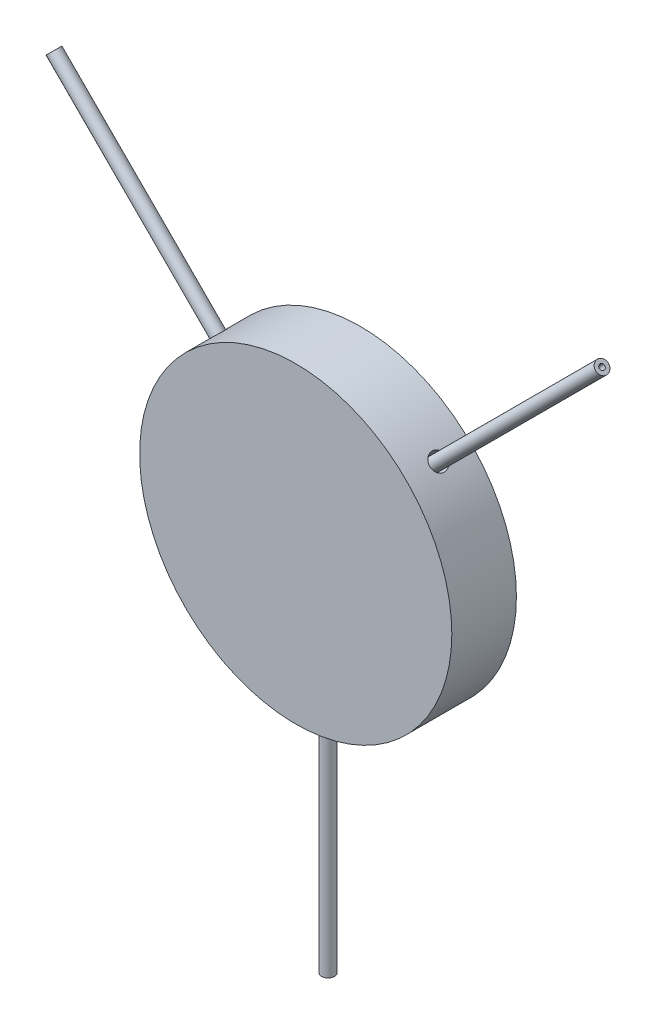
from build123d import *

# Parameters (mm, degrees)
SKETCH1_R           = 7.25
BOSS_EXTRUDE1_DEPTH = 3
CUT_EXTRUDE1_REACH  = 9.25
SKETCH2_R           = 0.4
CUT_EXTRUDE2_REACH  = 12.253
SKETCH3_R           = 0.4
CUT_EXTRUDE3_REACH  = 12.253
SKETCH4_R           = 0.4
BOSS_EXTRUDE2_START = 5
SKETCH5_R           = 0.3
SKETCH5_R_2         = 0.125
BOSS_EXTRUDE2_DEPTH = 13
BOSS_EXTRUDE3_START = 5
SKETCH6_R           = 0.3
SKETCH6_R_2         = 0.125
BOSS_EXTRUDE3_DEPTH = 13
BOSS_EXTRUDE4_START = -5
SKETCH7_R           = 0.3
SKETCH7_R_2         = 0.125
BOSS_EXTRUDE4_DEPTH = 13


with BuildPart() as part:
    # Sketch1 → Boss-Extrude1 (new body)
    with BuildSketch(Plane.XY):
        Circle(SKETCH1_R)
    extrude(amount=BOSS_EXTRUDE1_DEPTH)

    # Sketch2 → Cut-Extrude1 (cut, up to next)
    with BuildSketch(Plane(origin=(0, 0, 0), x_dir=(1, 0, 0), z_dir=(0, 1, 0)), mode=Mode.PRIVATE) as cut_extrude1_sk1:
        with Locations((0, -1.5)):
            Circle(SKETCH2_R)
    cut_extrude1_tool1 = extrude(cut_extrude1_sk1.sketch, amount=-CUT_EXTRUDE1_REACH, mode=Mode.PRIVATE) & part.part
    add(cut_extrude1_tool1.solids().sort_by_distance((0, 0, 1.5))[0], mode=Mode.SUBTRACT)

    # Sketch3 → Cut-Extrude2 (cut, up to next)
    with BuildSketch(Plane(origin=(0, 0, 0), x_dir=(0.707106781, 0.707106781, 0), z_dir=(-0.707106781, 0.707106781, 0)), mode=Mode.PRIVATE) as cut_extrude2_sk1:
        with Locations((0, -1.5)):
            Circle(SKETCH3_R)
    cut_extrude2_tool1 = extrude(cut_extrude2_sk1.sketch, amount=CUT_EXTRUDE2_REACH, mode=Mode.PRIVATE) & part.part
    add(cut_extrude2_tool1.solids().sort_by_distance((0, 0, 1.5))[0], mode=Mode.SUBTRACT)

    # Sketch4 → Cut-Extrude3 (cut, up to next)
    with BuildSketch(Plane(origin=(0, 0, 0), x_dir=(0.707106781, -0.707106781, 0), z_dir=(0.707106781, 0.707106781, 0)), mode=Mode.PRIVATE) as cut_extrude3_sk1:
        with Locations((0, -1.502186295)):
            Circle(SKETCH4_R)
    cut_extrude3_tool1 = extrude(cut_extrude3_sk1.sketch, amount=CUT_EXTRUDE3_REACH, mode=Mode.PRIVATE) & part.part
    add(cut_extrude3_tool1.solids().sort_by_distance((0, 0, 1.502186))[0], mode=Mode.SUBTRACT)


with BuildPart() as body_2:
    # Sketch5 → Boss-Extrude2 (new body)
    with BuildSketch(Plane(origin=(0, 0, 0), x_dir=(0.707106781, -0.707106781, 0), z_dir=(0.707106781, 0.707106781, 0)).offset(BOSS_EXTRUDE2_START)):
        with Locations((0, -1.502186295)):
            Circle(SKETCH5_R)
        with Locations((0, -1.502186295)):
            Circle(SKETCH5_R_2, mode=Mode.SUBTRACT)
    extrude(amount=BOSS_EXTRUDE2_DEPTH)


with BuildPart() as body_3:
    # Sketch6 → Boss-Extrude3 (new body)
    with BuildSketch(Plane(origin=(0, 0, 0), x_dir=(0.707106781, 0.707106781, 0), z_dir=(-0.707106781, 0.707106781, 0)).offset(BOSS_EXTRUDE3_START)):
        with Locations((0, -1.5)):
            Circle(SKETCH6_R)
        with Locations((0, -1.5)):
            Circle(SKETCH6_R_2, mode=Mode.SUBTRACT)
    extrude(amount=BOSS_EXTRUDE3_DEPTH)


with BuildPart() as body_4:
    # Sketch7 → Boss-Extrude4 (new body)
    with BuildSketch(Plane(origin=(0, 0, 0), x_dir=(1, 0, 0), z_dir=(0, 1, 0)).offset(BOSS_EXTRUDE4_START)):
        with Locations((0, -1.5)):
            Circle(SKETCH7_R)
        with Locations((0, -1.5)):
            Circle(SKETCH7_R_2, mode=Mode.SUBTRACT)
    extrude(amount=-BOSS_EXTRUDE4_DEPTH)


solid = Compound([part.part, body_2.part, body_3.part, body_4.part])
